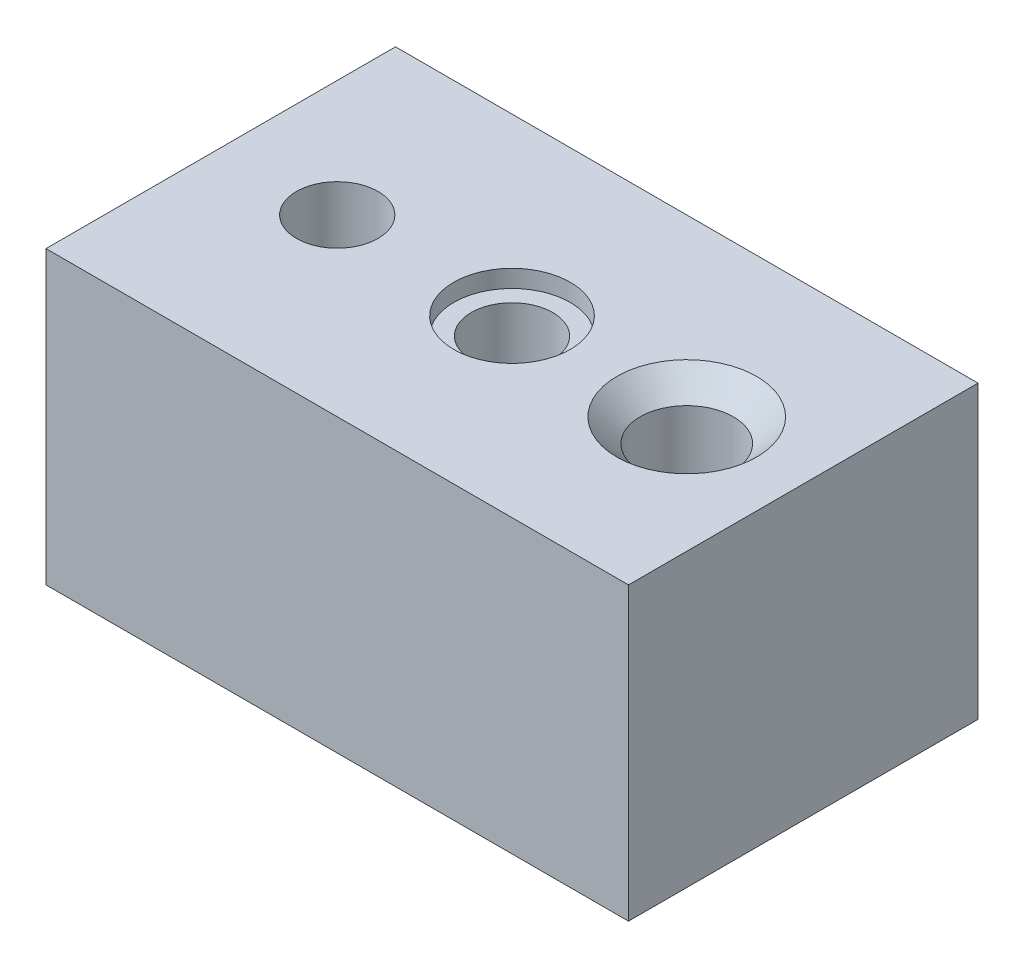
from build123d import *

# Parameters (mm, degrees)
SKETCH1_W                                       = 100
SKETCH1_H                                       = 60
BOSS_EXTRUDE2_DEPTH                             = 50
CBORE_FOR_M5_HEX_HEAD_BOLT1_D                   = 14
CBORE_FOR_M5_HEX_HEAD_BOLT1_DEPTH               = 16
CBORE_FOR_M5_HEX_HEAD_BOLT1_CBORE_D             = 20
CBORE_FOR_M5_HEX_HEAD_BOLT1_CBORE_DEPTH         = 3
CBORE_FOR_M5_HEX_HEAD_BOLT1_TIP                 = 4.206024333
CSK_FOR_M5_FLAT_HEAD_MACHINE_SCREW1_D           = 16
CSK_FOR_M5_FLAT_HEAD_MACHINE_SCREW1_DEPTH       = 16
CSK_FOR_M5_FLAT_HEAD_MACHINE_SCREW1_CSINK_D     = 24
CSK_FOR_M5_FLAT_HEAD_MACHINE_SCREW1_CSINK_ANGLE = 90
CSK_FOR_M5_FLAT_HEAD_MACHINE_SCREW1_TIP         = 4.806884952
M16X2_0_TAPPED_HOLE1_D                          = 14


with BuildPart() as part:
    # Sketch1 → Boss-Extrude2 (new body)
    with BuildSketch(Plane(origin=(0, 0, 0), x_dir=(1, 0, 0), z_dir=(0, 1, 0))):
        with Locations((50, 30)):
            Rectangle(SKETCH1_W, SKETCH1_H)
    extrude(amount=BOSS_EXTRUDE2_DEPTH)

    # CBORE for M5 Hex Head Bolt1
    with Locations(Plane(origin=(0, 50, 0), x_dir=(1, 0, 0), z_dir=(0, 1, 0))):
        with Locations((50, 30)):
            CounterBoreHole(CBORE_FOR_M5_HEX_HEAD_BOLT1_D / 2, CBORE_FOR_M5_HEX_HEAD_BOLT1_CBORE_D / 2, CBORE_FOR_M5_HEX_HEAD_BOLT1_CBORE_DEPTH, depth=CBORE_FOR_M5_HEX_HEAD_BOLT1_DEPTH)
            with Locations((0, 0, -(CBORE_FOR_M5_HEX_HEAD_BOLT1_DEPTH + CBORE_FOR_M5_HEX_HEAD_BOLT1_TIP / 2))):  # 118° drill point
                Cone(0, CBORE_FOR_M5_HEX_HEAD_BOLT1_D / 2, CBORE_FOR_M5_HEX_HEAD_BOLT1_TIP, mode=Mode.SUBTRACT)

    # CSK for M5 Flat Head Machine Screw1
    with Locations(Plane(origin=(0, 50, 0), x_dir=(1, 0, 0), z_dir=(0, 1, 0))):
        with Locations((80, 30)):
            CounterSinkHole(CSK_FOR_M5_FLAT_HEAD_MACHINE_SCREW1_D / 2, CSK_FOR_M5_FLAT_HEAD_MACHINE_SCREW1_CSINK_D / 2, depth=CSK_FOR_M5_FLAT_HEAD_MACHINE_SCREW1_DEPTH, counter_sink_angle=CSK_FOR_M5_FLAT_HEAD_MACHINE_SCREW1_CSINK_ANGLE)
            with Locations((0, 0, -(CSK_FOR_M5_FLAT_HEAD_MACHINE_SCREW1_DEPTH + CSK_FOR_M5_FLAT_HEAD_MACHINE_SCREW1_TIP / 2))):  # 118° drill point
                Cone(0, CSK_FOR_M5_FLAT_HEAD_MACHINE_SCREW1_D / 2, CSK_FOR_M5_FLAT_HEAD_MACHINE_SCREW1_TIP, mode=Mode.SUBTRACT)

    # M16x2.0 Tapped Hole1 (through all)
    with Locations(Plane(origin=(0, 50, 0), x_dir=(1, 0, 0), z_dir=(0, 1, 0))):
        with Locations((20, 30)):
            Hole(M16X2_0_TAPPED_HOLE1_D / 2)


solid = part.part
